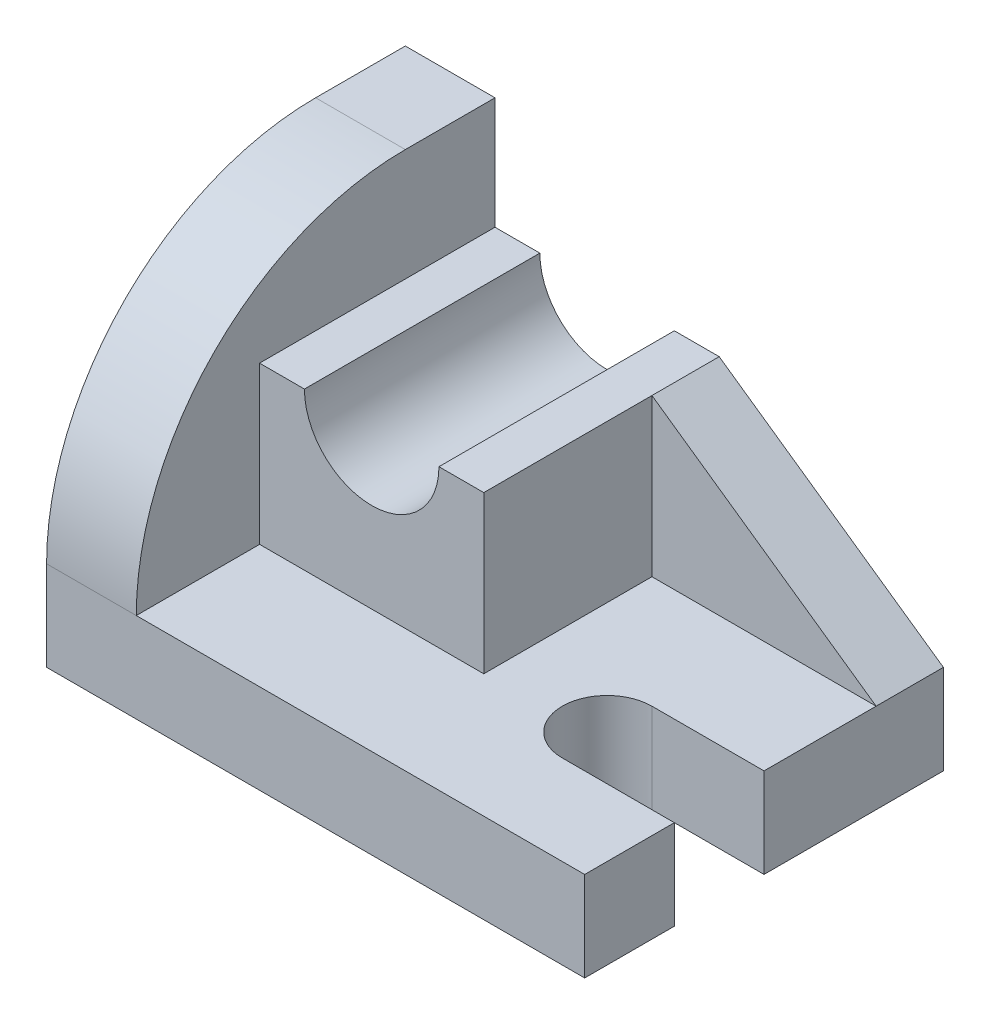
from build123d import *

# Parameters (mm, degrees)
SKETCH1_W           = 96
SKETCH1_H           = 64
BOSS_EXTRUDE1_DEPTH = 16
SKETCH2_W           = 16
SKETCH2_H           = 64
BOSS_EXTRUDE2_DEPTH = 48
FILLET3_R           = 48
SKETCH3_W           = 40
SKETCH3_H           = 42
BOSS_EXTRUDE3_DEPTH = 28
SKETCH4_R           = 12
CUT_EXTRUDE1_DEPTH  = 43
BOSS_EXTRUDE4_DEPTH = 12
CUT_EXTRUDE2_DEPTH  = 17


with BuildPart() as part:
    # Sketch1 → Boss-Extrude1 (new body)
    with BuildSketch(Plane(origin=(0, 0, 0), x_dir=(1, 0, 0), z_dir=(0, 1, 0))):
        Rectangle(SKETCH1_W, SKETCH1_H)
    extrude(amount=BOSS_EXTRUDE1_DEPTH)

    # Sketch2 → Boss-Extrude2 (add)
    with BuildSketch(Plane(origin=(0, 16, 0), x_dir=(1, 0, 0), z_dir=(0, 1, 0))):
        with Locations((-40, 0)):
            Rectangle(SKETCH2_W, SKETCH2_H)
    extrude(amount=BOSS_EXTRUDE2_DEPTH)

    # Fillet3
    fillet3_edges = [part.edges().sort_by_distance(p)[0] for p in [
        (-40, 64, 32),
    ]]
    fillet(fillet3_edges, radius=FILLET3_R)

    # Sketch3 → Boss-Extrude3 (add)
    with BuildSketch(Plane(origin=(0, 16, 0), x_dir=(1, 0, 0), z_dir=(0, 1, 0))):
        with Locations((-12, 11)):
            Rectangle(SKETCH3_W, SKETCH3_H)
    extrude(amount=BOSS_EXTRUDE3_DEPTH)

    # Sketch4 → Cut-Extrude1 (cut, through all)
    with BuildSketch(Plane.XY.offset(10)):
        with Locations((-12, 44)):
            Circle(SKETCH4_R)
    extrude(amount=-CUT_EXTRUDE1_DEPTH, mode=Mode.SUBTRACT)

    # Sketch5 → Boss-Extrude4 (add)
    with BuildSketch(Plane(origin=(0, 0, -32), x_dir=(-1, 0, 0), z_dir=(0, 0, -1))):
        Polygon((-8, 16), (-8, 44), (-48, 16), align=None)
    extrude(amount=-BOSS_EXTRUDE4_DEPTH)

    # Sketch6 → Cut-Extrude2 (cut, through all)
    with BuildSketch(Plane(origin=(0, 16, 0), x_dir=(1, 0, 0), z_dir=(0, 1, 0))):
        with BuildLine():
            Line((28, 0), (48, 0))
            ThreePointArc((48, 0), (56, -8), (48, -16))
            Line((48, -16), (28, -16))
            ThreePointArc((28, -16), (20, -8), (28, 0))
        make_face()
    extrude(amount=-CUT_EXTRUDE2_DEPTH, mode=Mode.SUBTRACT)


solid = part.part
